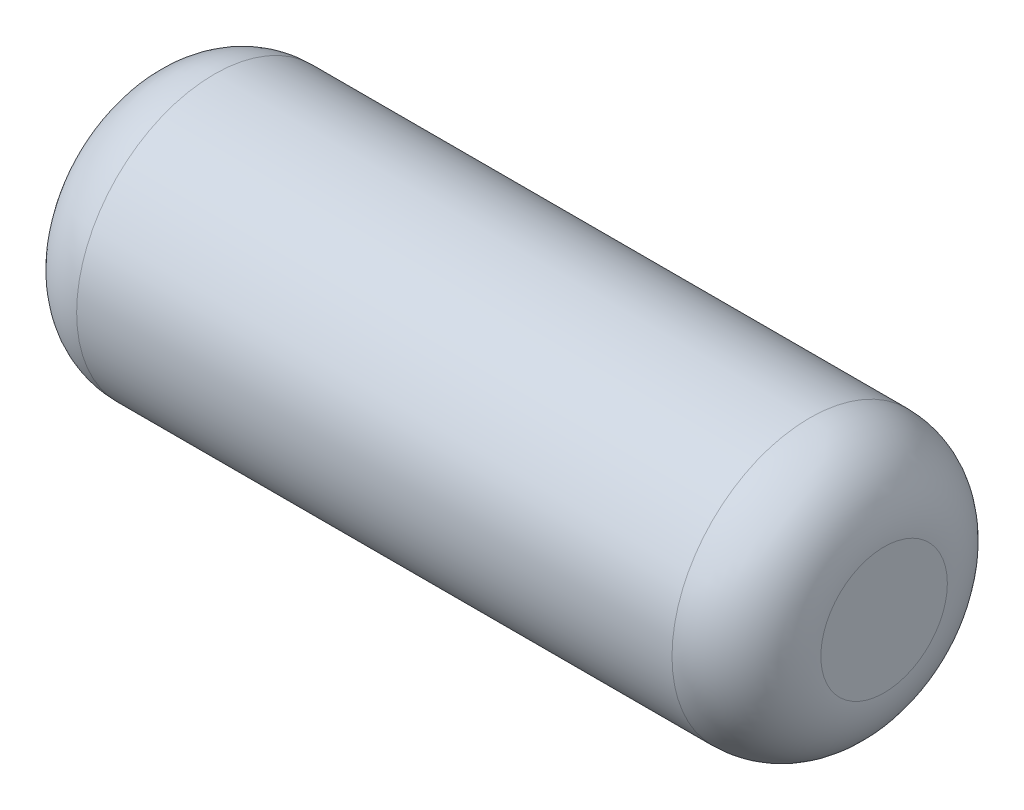
from build123d import *

# Parameters (mm, degrees)
SKETCH1_R           = 4.699
BOSS_EXTRUDE1_DEPTH = 12.7
FILLET1_R           = 2.54


with BuildPart() as part:
    # Sketch1 → Boss-Extrude1 (new body, symmetric)
    with BuildSketch(Plane(origin=(0, 0, 0), x_dir=(0, 0, -1), z_dir=(1, 0, 0))):
        Circle(SKETCH1_R)
    extrude(amount=BOSS_EXTRUDE1_DEPTH, both=True)

    # Fillet1
    fillet1_edges = [part.edges().sort_by_distance(p)[0] for p in [
        (-12.7, 0, 4.699),
        (12.7, 0, 4.699),
    ]]
    fillet(fillet1_edges, radius=FILLET1_R)


solid = part.part
